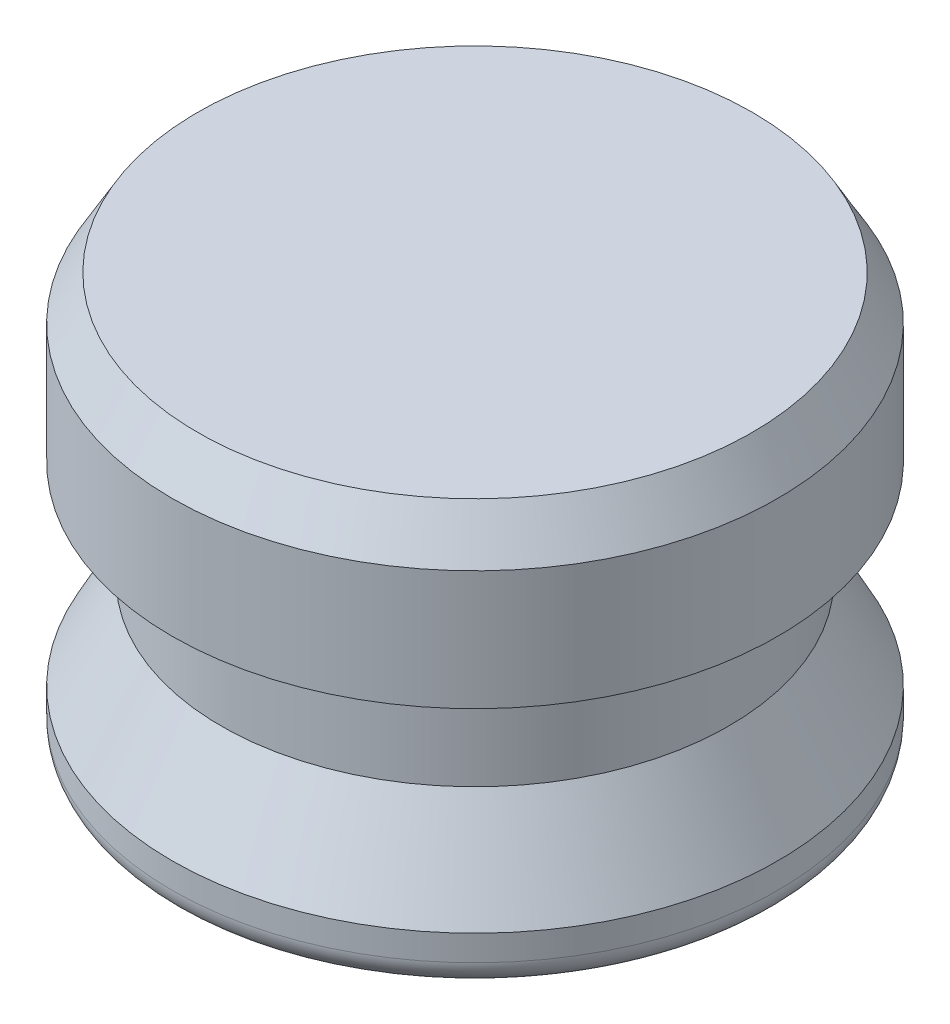
from build123d import *

# Parameters (mm, degrees)
FILLET1_R      = 0.79375
CHAMFER1_SIZE  = 0.79375
CHAMFER1_SIZE2 = 1.374815329


with BuildPart() as part:
    # Sketch1 → Revolve1 (revolve)
    with BuildSketch(Plane.XY):
        Polygon((0, 0), (-9.398, 0), (-9.398, 1.5875), (-7.874, 4.445), (-7.874, 7.62), (-9.398, 7.62), (-9.398, 12.7), (0, 12.7), align=None)
    revolve(axis=Axis((0, 0, 0), (0, 1, 0)))

    # Fillet1
    fillet1_edges = [part.edges().sort_by_distance(p)[0] for p in [
        (9.398, 0, 0),
    ]]
    fillet(fillet1_edges, radius=FILLET1_R)

    # Chamfer1
    chamfer1_edges = [part.edges().sort_by_distance(p)[0] for p in [
        (9.398, 12.7, 0),
    ]]
    chamfer1_side = [part.faces().sort_by_distance(p)[0] for p in [
        (0, 12.7, 0),
    ]]
    chamfer(chamfer1_edges, length=CHAMFER1_SIZE, length2=CHAMFER1_SIZE2, reference=chamfer1_side[0])


solid = part.part
